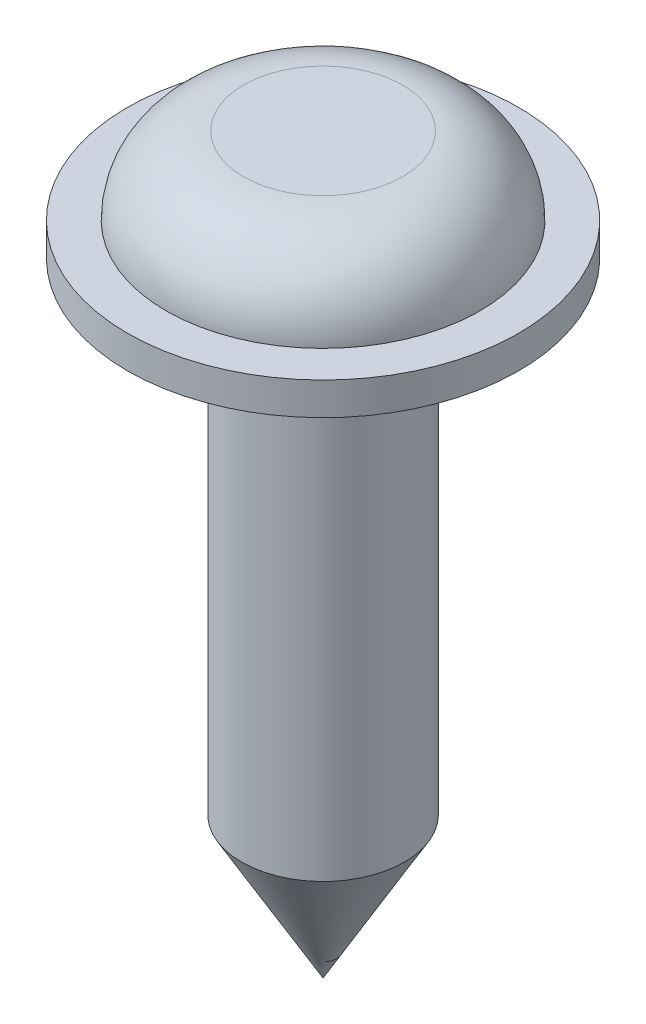
from build123d import *


with BuildPart() as part:
    # Esquisse1 → Révolution1 (revolve)
    with BuildSketch(Plane.XY):
        with BuildLine():
            Line((0, 0), (1, 1.732050808))
            Line((1, 1.732050808), (1, 7.65))
            Line((1, 7.65), (2.4, 7.65))
            Line((2.4, 7.65), (2.4, 8.05))
            Line((2.4, 8.05), (1.925, 8.05))
            ThreePointArc((1.925, 8.05), (1.646751442, 8.721751442), (0.975, 9))
            Line((0.975, 9), (0, 9))
            Line((0, 9), (0, 0))
        make_face()
    revolve(axis=Axis((0, 9, 0), (0, -1, 0)))


solid = part.part
